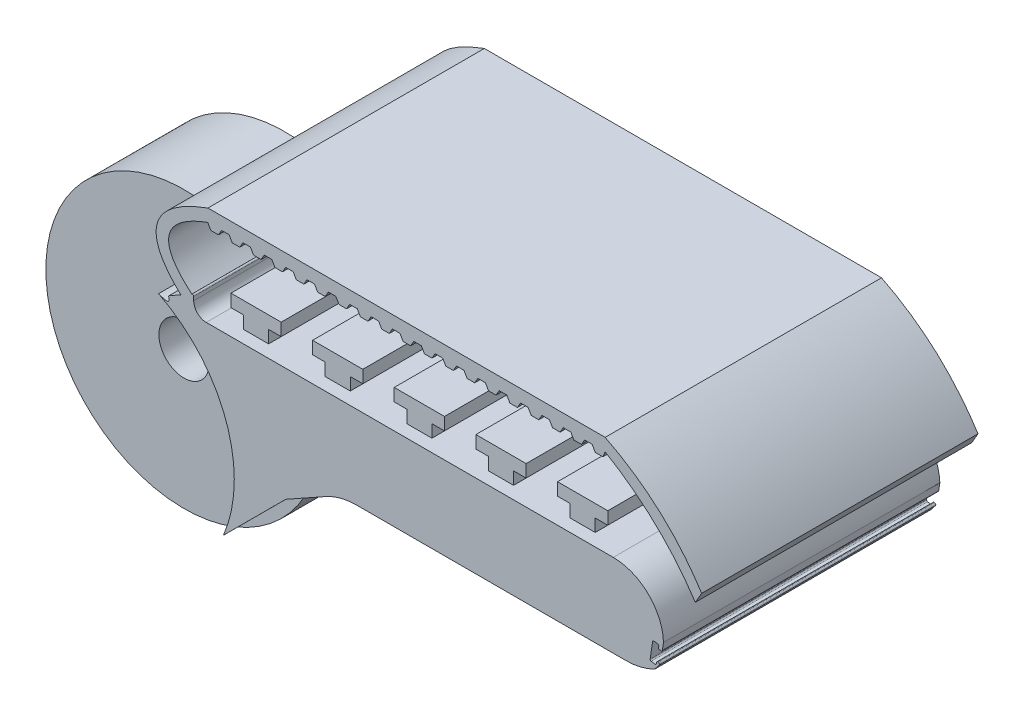
from build123d import *

# Parameters (mm, degrees)
GRIPPER_BODY_DEPTH                     = 11
SKETCH7_R                              = 11
CUT_EXTRUDE1_DEPTH                     = 7
SKETCH8_R                              = 11
CUT_EXTRUDE2_DEPTH                     = 7
SKETCH5_W                              = 2
SKETCH5_H                              = 20
SILICON_HOLDER_BOTTOM_HALF_DEPTH       = 1
SKETCH6_W                              = 4
SKETCH6_H                              = 20
SILICON_HOLDER_TOP_HALF_DEPTH          = 1
SILICON_HOLDER_PATTERN_COUNT           = 5
SILICON_HOLDER_PATTERN_PITCH           = 6.5
JOINT_PIN_HOLE_REACH                   = 17
SKETCH9_R                              = 2
SKETCH11_R                             = 0.7
TENDON_HOLE_DEPTH                      = 27.253350117
SKETCH12_W                             = 5
SKETCH12_H                             = 4
ELASTIC_HOLDER_DEPTH                   = 4
SKETCH14_W                             = 8
SKETCH14_H                             = 4
BOSS_EXTRUDE4_DEPTH                    = 2
FILLET8_R                              = 0.5
MOULD_DEPTH                            = 22
EXTRA_MOULD_AREA_ONTO_FINGERNAIL_DEPTH = 22


with BuildPart() as part:
    # Sketch1 → Gripper Body (new body, symmetric)
    with BuildSketch(Plane.XY):
        with BuildLine():
            Line((-16.865812618, -0.519577909), (-13.42367449, -0.519577909))
            ThreePointArc((-13.42367449, -0.519577909), (-10.64489906, -1.642355792), (-9.426097428, -4.380374353))
            Line((-9.426097428, -4.380374353), (-9.51772527, -4.972912515))
            ThreePointArc((-9.51772527, -4.972912515), (-9.557645449, -5.038440024), (-9.632245935, -5.056391144))
            Line((-9.632245935, -5.056391144), (-9.829353157, -5.025066421))
            Line((-9.829353157, -5.025066421), (-9.798088552, -4.828337486))
            ThreePointArc((-9.798088552, -4.828337486), (-9.816151945, -4.753583285), (-9.881943522, -4.713759357))
            Line((-9.881943522, -4.713759357), (-10.177570739, -4.669196391))
            ThreePointArc((-10.177570739, -4.669196391), (-10.251857248, -4.687618632), (-10.291359252, -4.753173617))
            Line((-10.291359252, -4.753173617), (-10.488529016, -6.061182351))
            ThreePointArc((-10.488529016, -6.061182351), (-10.469833617, -6.135837217), (-10.403644246, -6.175103413))
            Line((-10.403644246, -6.175103413), (-10.107009237, -6.21703957))
            ThreePointArc((-10.107009237, -6.21703957), (-10.032894815, -6.197936775), (-9.99399572, -6.132022249))
            Line((-9.99399572, -6.132022249), (-9.980592887, -6.037217435))
            ThreePointArc((-9.980592887, -6.037217435), (-9.940017371, -5.97006889), (-9.863470344, -5.952868535))
            Line((-9.863470344, -5.952868535), (-9.83222647, -5.958620991))
            ThreePointArc((-9.83222647, -5.958620991), (-9.756940681, -6.021222164), (-9.771189341, -6.118092348))
            Line((-9.771189341, -6.118092348), (-10.11691784, -6.565744053))
            ThreePointArc((-10.11691784, -6.565744053), (-11.235027846, -6.985520452), (-12.420791966, -7.128158673))
            Line((-12.420791966, -7.128158673), (-33.860461483, -7.128158673))
            ThreePointArc((-33.860461483, -7.128158673), (-35.121193977, -7.289713305), (-36.300455601, -7.763937241))
            Line((-36.300455601, -7.763937241), (-39.495287424, -9.550136906))
            Line((-39.495287424, -9.550136906), (-44.445034893, -14.499884374))
            ThreePointArc((-44.445034893, -14.499884374), (-44.449306594, -14.50495752), (-44.453582252, -14.510027332))
            ThreePointArc((-44.453582252, -14.510027332), (-64.919905245, -14.031414924), (-49.616149263, -0.433823243))
            add(Edge.make_bspline(
                [(-48.821045939, -0.226062514), (-48.562499324, -0.85935481), (-49.616149263, -0.433823243)],
                knots=[0, 0, 0, 1, 1, 1], degree=2))
            ThreePointArc((-48.821045939, -0.226062514), (-48.805177845, -0.181157067), (-48.770337725, -0.148684591))
            Line((-48.770337725, -0.148684591), (-46.973041652, 0.856166312))
            ThreePointArc((-46.973041652, 0.856166312), (-46.873645269, 0.855137284), (-46.82424177, 0.768881883))
            Line((-46.82424177, 0.768881883), (-46.82424177, 0.480422091))
            ThreePointArc((-46.82424177, 0.480422091), (-46.531348551, -0.22668469), (-45.82424177, -0.519577909))
            Line((-45.82424177, -0.519577909), (-16.865812618, -0.519577909))
        make_face()
    extrude(amount=GRIPPER_BODY_DEPTH, both=True)

    # Sketch7 → Cut-Extrude1 (cut)
    with BuildSketch(Plane.XY.offset(11)):
        with Locations((-54.592572221, -10.243778112)):
            Circle(SKETCH7_R)
    extrude(amount=-CUT_EXTRUDE1_DEPTH, mode=Mode.SUBTRACT)

    # Sketch8 → Cut-Extrude2 (cut)
    with BuildSketch(Plane(origin=(0, 0, -11), x_dir=(-1, 0, 0), z_dir=(0, 0, -1))):
        with Locations((54.592572221, -10.243778112)):
            Circle(SKETCH8_R)
    extrude(amount=-CUT_EXTRUDE2_DEPTH, mode=Mode.SUBTRACT)

    # Sketch5 → Silicon Holder Bottom Half (add)
    with BuildSketch(Plane(origin=(0, -0.519577909, 0), x_dir=(1, 0, 0), z_dir=(0, 1, 0))):
        with Locations((-42.860244271, 0)):
            Rectangle(SKETCH5_W, SKETCH5_H)
    silicon_holder_bottom_half = extrude(amount=SILICON_HOLDER_BOTTOM_HALF_DEPTH)

    # Sketch6 → Silicon Holder Top Half (add)
    with BuildSketch(Plane(origin=(0, 0.480422091, 0), x_dir=(1, 0, 0), z_dir=(0, 1, 0))):
        with Locations((-42.860244271, 0)):
            Rectangle(SKETCH6_W, SKETCH6_H)
    silicon_holder_top_half = extrude(amount=SILICON_HOLDER_TOP_HALF_DEPTH)

    # Silicon Holder Pattern: Silicon Holder Bottom Half, Silicon Holder Top Half ×5
    with Locations(*[(i * SILICON_HOLDER_PATTERN_PITCH, 0, 0) for i in range(1, SILICON_HOLDER_PATTERN_COUNT)]):
        add(silicon_holder_bottom_half)
        add(silicon_holder_top_half)

    # Sketch9 → Joint Pin Hole (cut, up to next)
    with BuildSketch(Plane.XY.offset(4), mode=Mode.PRIVATE) as joint_pin_hole_sk1:
        with Locations((-54.592572221, -10.243778112)):
            Circle(SKETCH9_R)
    joint_pin_hole_tool1 = extrude(joint_pin_hole_sk1.sketch, amount=-JOINT_PIN_HOLE_REACH, mode=Mode.PRIVATE) & part.part
    add(joint_pin_hole_tool1.solids().sort_by_distance((-54.592572, -10.243778, 4))[0], mode=Mode.SUBTRACT)

    # Sketch11 → Tendon Hole (cut, through all)
    with BuildSketch(Plane(origin=(-14.972575259, 14.972575259, 0), x_dir=(0, 0, -1), z_dir=(0.707106781, -0.707106781, 0))):
        with Locations((0, -35.609623866)):
            Circle(SKETCH11_R)
    extrude(amount=-TENDON_HOLE_DEPTH, mode=Mode.SUBTRACT)

    # Sketch12 → Elastic Holder (add)
    with BuildSketch(Plane.XZ.offset(7.128158673)):
        with Locations((-22.825414443, 0)):
            Rectangle(SKETCH12_W, SKETCH12_H)
    extrude(amount=ELASTIC_HOLDER_DEPTH)

    # Sketch14 → Boss-Extrude4 (add)
    with BuildSketch(Plane.XZ.offset(11.128158673)):
        with Locations((-21.325414443, 0)):
            Rectangle(SKETCH14_W, SKETCH14_H)
    extrude(amount=BOSS_EXTRUDE4_DEPTH)

    # Fillet8
    fillet8_edges = [part.edges().sort_by_distance(p)[0] for p in [
        (-20.325414443, -7.128158673, 0),
        (-20.325414443, -9.128158673, -2),
        (-22.825414443, -7.128158673, 2),
        (-20.325414443, -9.128158673, 2),
        (-25.325414443, -7.128158673, 0),
        (-25.325414443, -10.128158673, 2),
        (-22.825414443, -7.128158673, -2),
        (-25.325414443, -10.128158673, -2),
        (-18.825414443, -11.128158673, -2),
        (-17.325414443, -12.128158673, -2),
        (-18.825414443, -11.128158673, 2),
        (-17.325414443, -12.128158673, 2),
        (-25.325414443, -13.128158673, 0),
        (-21.325414443, -13.128158673, -2),
        (-17.325414443, -13.128158673, 0),
        (-21.325414443, -13.128158673, 2),
    ]]
    fillet(fillet8_edges, radius=FILLET8_R)

    # Sketch17 → Mould (add)
    with BuildSketch(Plane.XY.offset(11)):
        with BuildLine():
            Line((-47.845885938, 0.368167488), (-46.973041652, 0.856166312))
            add(Edge.make_bspline(
                [(-46.973041652, 0.856166312), (-51.219669412, 4.427786306), (-45.704865034, 6.433924097)],
                knots=[0, 0, 0, 1, 1, 1], degree=2))
            Line((-45.704865034, 6.433924097), (-45.454865034, 6.000911396))
            Line((-45.454865034, 6.000911396), (-44.854865034, 6.000911396))
            Line((-44.854865034, 6.000911396), (-44.604865034, 6.433924097))
            Line((-44.604865034, 6.433924097), (-44.004865034, 6.433924097))
            Line((-44.004865034, 6.433924097), (-43.754865034, 6.000911396))
            Line((-43.754865034, 6.000911396), (-43.154865034, 6.000911396))
            Line((-43.154865034, 6.000911396), (-42.904865034, 6.433924097))
            Line((-42.904865034, 6.433924097), (-42.304865034, 6.433924097))
            Line((-42.304865034, 6.433924097), (-42.054865034, 6.000911396))
            Line((-42.054865034, 6.000911396), (-41.454865034, 6.000911396))
            Line((-41.454865034, 6.000911396), (-41.204865034, 6.433924097))
            Line((-41.204865034, 6.433924097), (-40.604865034, 6.433924097))
            Line((-40.604865034, 6.433924097), (-40.354865034, 6.000911396))
            Line((-40.354865034, 6.000911396), (-39.754865034, 6.000911396))
            Line((-39.754865034, 6.000911396), (-39.504865034, 6.433924097))
            Line((-39.504865034, 6.433924097), (-38.904865034, 6.433924097))
            Line((-38.904865034, 6.433924097), (-38.654865034, 6.000911396))
            Line((-38.654865034, 6.000911396), (-38.054865034, 6.000911396))
            Line((-38.054865034, 6.000911396), (-37.804865034, 6.433924097))
            Line((-37.804865034, 6.433924097), (-37.204865034, 6.433924097))
            Line((-37.204865034, 6.433924097), (-36.954865034, 6.000911396))
            Line((-36.954865034, 6.000911396), (-36.354865034, 6.000911396))
            Line((-36.354865034, 6.000911396), (-36.104865034, 6.433924097))
            Line((-36.104865034, 6.433924097), (-35.504865034, 6.433924097))
            Line((-35.504865034, 6.433924097), (-35.254865034, 6.000911396))
            Line((-35.254865034, 6.000911396), (-34.654865034, 6.000911396))
            Line((-34.654865034, 6.000911396), (-34.404865034, 6.433924097))
            Line((-34.404865034, 6.433924097), (-33.804865034, 6.433924097))
            Line((-33.804865034, 6.433924097), (-33.554865034, 6.000911396))
            Line((-33.554865034, 6.000911396), (-32.954865034, 6.000911396))
            Line((-32.954865034, 6.000911396), (-32.704865034, 6.433924097))
            Line((-32.704865034, 6.433924097), (-32.104865034, 6.433924097))
            Line((-32.104865034, 6.433924097), (-31.854865034, 6.000911396))
            Line((-31.854865034, 6.000911396), (-31.254865034, 6.000911396))
            Line((-31.254865034, 6.000911396), (-31.004865034, 6.433924097))
            Line((-31.004865034, 6.433924097), (-30.404865034, 6.433924097))
            Line((-30.404865034, 6.433924097), (-30.154865034, 6.000911396))
            Line((-30.154865034, 6.000911396), (-29.554865034, 6.000911396))
            Line((-29.554865034, 6.000911396), (-29.304865034, 6.433924097))
            Line((-29.304865034, 6.433924097), (-28.704865034, 6.433924097))
            Line((-28.704865034, 6.433924097), (-28.454865034, 6.000911396))
            Line((-28.454865034, 6.000911396), (-27.854865034, 6.000911396))
            Line((-27.854865034, 6.000911396), (-27.604865034, 6.433924097))
            Line((-27.604865034, 6.433924097), (-27.004865034, 6.433924097))
            Line((-27.004865034, 6.433924097), (-26.754865034, 6.000911396))
            Line((-26.754865034, 6.000911396), (-26.154865034, 6.000911396))
            Line((-26.154865034, 6.000911396), (-25.904865034, 6.433924097))
            Line((-25.904865034, 6.433924097), (-25.304865034, 6.433924097))
            Line((-25.304865034, 6.433924097), (-25.054865034, 6.000911396))
            Line((-25.054865034, 6.000911396), (-24.454865034, 6.000911396))
            Line((-24.454865034, 6.000911396), (-24.204865034, 6.433924097))
            Line((-24.204865034, 6.433924097), (-23.604865034, 6.433924097))
            Line((-23.604865034, 6.433924097), (-23.354865034, 6.000911396))
            Line((-23.354865034, 6.000911396), (-22.754865034, 6.000911396))
            Line((-22.754865034, 6.000911396), (-22.504865034, 6.433924097))
            Line((-22.504865034, 6.433924097), (-21.904865034, 6.433924097))
            Line((-21.904865034, 6.433924097), (-21.654865034, 6.000911396))
            Line((-21.654865034, 6.000911396), (-21.054865034, 6.000911396))
            Line((-21.054865034, 6.000911396), (-20.804865034, 6.433924097))
            Line((-20.804865034, 6.433924097), (-20.204865034, 6.433924097))
            Line((-20.204865034, 6.433924097), (-19.954865034, 6.000911396))
            Line((-19.954865034, 6.000911396), (-19.354865034, 6.000911396))
            Line((-19.354865034, 6.000911396), (-19.104865034, 6.433924097))
            Line((-19.104865034, 6.433924097), (-18.504865034, 6.433924097))
            Line((-18.504865034, 6.433924097), (-18.254865034, 6.000911396))
            Line((-18.254865034, 6.000911396), (-17.654865034, 6.000911396))
            Line((-17.654865034, 6.000911396), (-17.404865034, 6.433924097))
            Line((-17.404865034, 6.433924097), (-16.804865034, 6.433924097))
            Line((-16.804865034, 6.433924097), (-16.554865034, 6.000911396))
            Line((-16.554865034, 6.000911396), (-15.954865034, 6.000911396))
            Line((-15.954865034, 6.000911396), (-15.704865034, 6.433924097))
            Line((-15.704865034, 6.433924097), (-15.104865034, 6.433924097))
            Line((-15.104865034, 6.433924097), (-14.854865034, 6.000911396))
            Line((-14.854865034, 6.000911396), (-14.254865034, 6.000911396))
            Line((-14.254865034, 6.000911396), (-14.06841355, 6.433924097))
            Line((-14.06841355, 6.433924097), (-14.06841355, 7.433793916))
            Line((-14.06841355, 7.433793916), (-45.688729811, 7.433793916))
            add(Edge.make_bspline(
                [(-47.845885938, 0.368167488), (-52.664965642, 4.897835476), (-45.688729811, 7.433793916)],
                knots=[0, 0, 0, 1, 1, 1], degree=2))
        make_face()
    extrude(amount=-MOULD_DEPTH)

    # Sketch18 → Extra Mould Area onto Fingernail (add)
    with BuildSketch(Plane(origin=(0, 0, -11), x_dir=(-1, 0, 0), z_dir=(0, 0, -1))):
        with BuildLine():
            Line((14.06841355, 7.433793916), (14.06841355, 6.433924097))
            add(Edge.make_bspline(
                [(14.06841355, 6.433924097), (9.693645875, 3.865548292), (6.889902325, -0.348600936)],
                knots=[0, 0, 0, 1, 1, 1], degree=2))
            Line((6.889902325, -0.348600936), (6.389902325, 0.517424467))
            add(Edge.make_bspline(
                [(6.389902325, 0.517424467), (9.26307209, 5.014390965), (14.06841355, 7.433793916)],
                knots=[0, 0, 0, 1, 1, 1], degree=2))
        make_face()
    extrude(amount=-EXTRA_MOULD_AREA_ONTO_FINGERNAIL_DEPTH)


solid = part.part
